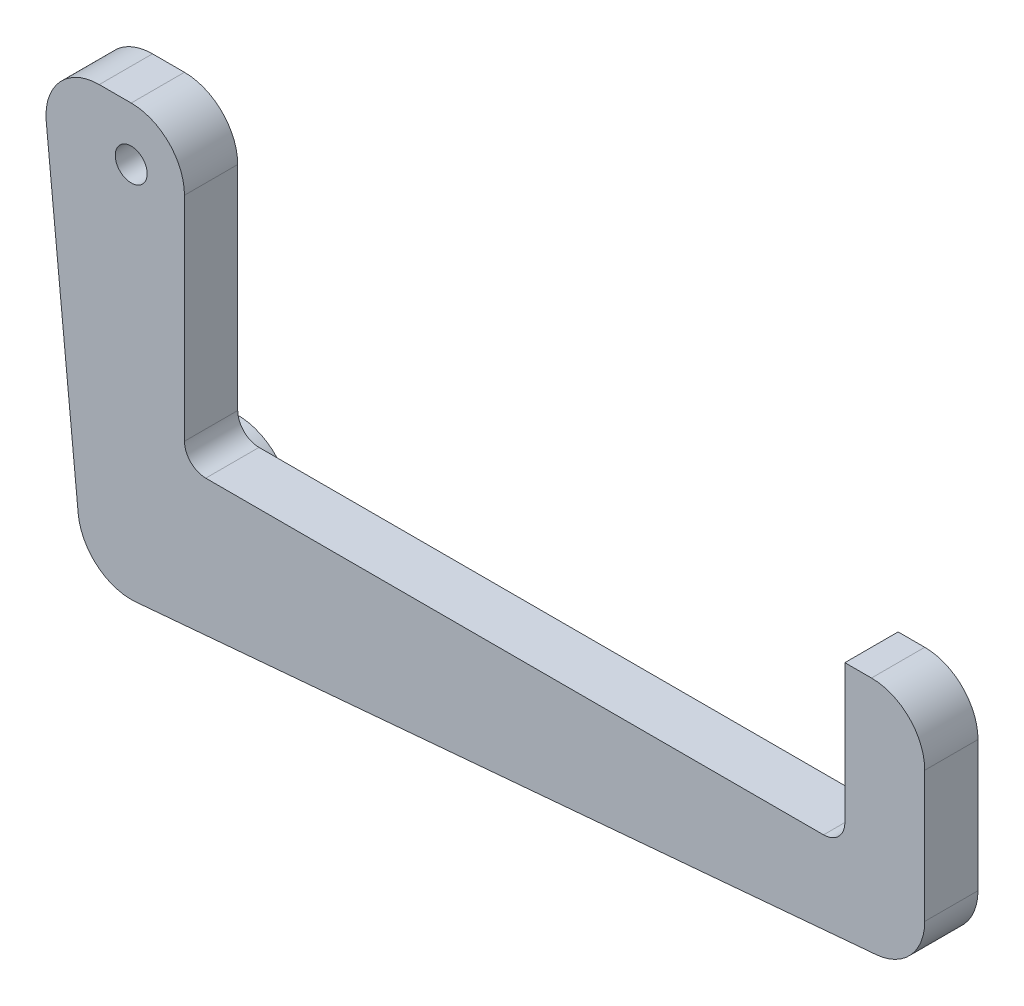
from build123d import *

# Parameters (mm, degrees)
SKETCH1_R           = 1.905
BOSS_EXTRUDE1_DEPTH = 6.35
SKETCH3_R           = 6.35
BOSS_EXTRUDE2_DEPTH = 12.7
BOSS_EXTRUDE3_DEPTH = 6.35


with BuildPart() as part:
    # Sketch1 → Boss-Extrude1 (new body)
    with BuildSketch(Plane.XY):
        with BuildLine():
            Line((12.7, -10.16), (12.7, -48.731538364))
            ThreePointArc((12.7, -48.731538364), (14.760002182, -53.413249452), (19.603438966, -55.057374697))
            Line((19.603438966, -55.057374697), (107.868438966, -47.33518781))
            ThreePointArc((107.868438966, -47.33518781), (111.996711089, -45.299349296), (113.665, -41.009351478))
            Line((113.665, -41.009351478), (113.665, -25.4))
            ThreePointArc((113.665, -25.4), (111.805128061, -20.909871939), (107.315, -19.05))
            Line((107.315, -19.05), (104.14, -19.05))
            Line((104.14, -19.05), (104.14, -35.56))
            ThreePointArc((104.14, -35.56), (103.396051224, -37.356051224), (101.6, -38.1))
            Line((101.6, -38.1), (27.94, -38.1))
            ThreePointArc((27.94, -38.1), (26.143948776, -37.356051224), (25.4, -35.56))
            Line((25.4, -35.56), (25.4, -10.16))
            ThreePointArc((25.4, -10.16), (23.540128061, -5.669871939), (19.05, -3.81))
            ThreePointArc((19.05, -3.81), (14.559871939, -5.669871939), (12.7, -10.16))
        make_face()
        with Locations((19.05, -10.16)):
            Circle(SKETCH1_R, mode=Mode.SUBTRACT)
    extrude(amount=BOSS_EXTRUDE1_DEPTH)

    # Sketch3 → Boss-Extrude2 (add)
    with BuildSketch(Plane.XY.offset(6.35)):
        with Locations(Location((19.05, -48.731538364, 0), (0, 0, 180))):
            Circle(SKETCH3_R)
    extrude(amount=-BOSS_EXTRUDE2_DEPTH)

    # Sketch6 → Boss-Extrude3 (add)
    with BuildSketch(Plane.XY.offset(6.35)):
        with BuildLine():
            Line((12.730753591, -49.355737704), (8.920753591, -10.784199341))
            ThreePointArc((8.920753591, -10.784199341), (10.534356271, -5.896267235), (15.24, -3.81))
            Line((15.24, -3.81), (19.05, -3.81))
            ThreePointArc((19.05, -3.81), (14.559871939, -5.669871939), (12.7, -10.16))
            Line((12.7, -10.16), (12.7, -48.731538364))
            ThreePointArc((12.7, -48.731538364), (12.707693058, -49.044016603), (12.730753591, -49.355737704))
        make_face()
    extrude(amount=-BOSS_EXTRUDE3_DEPTH)


solid = part.part
